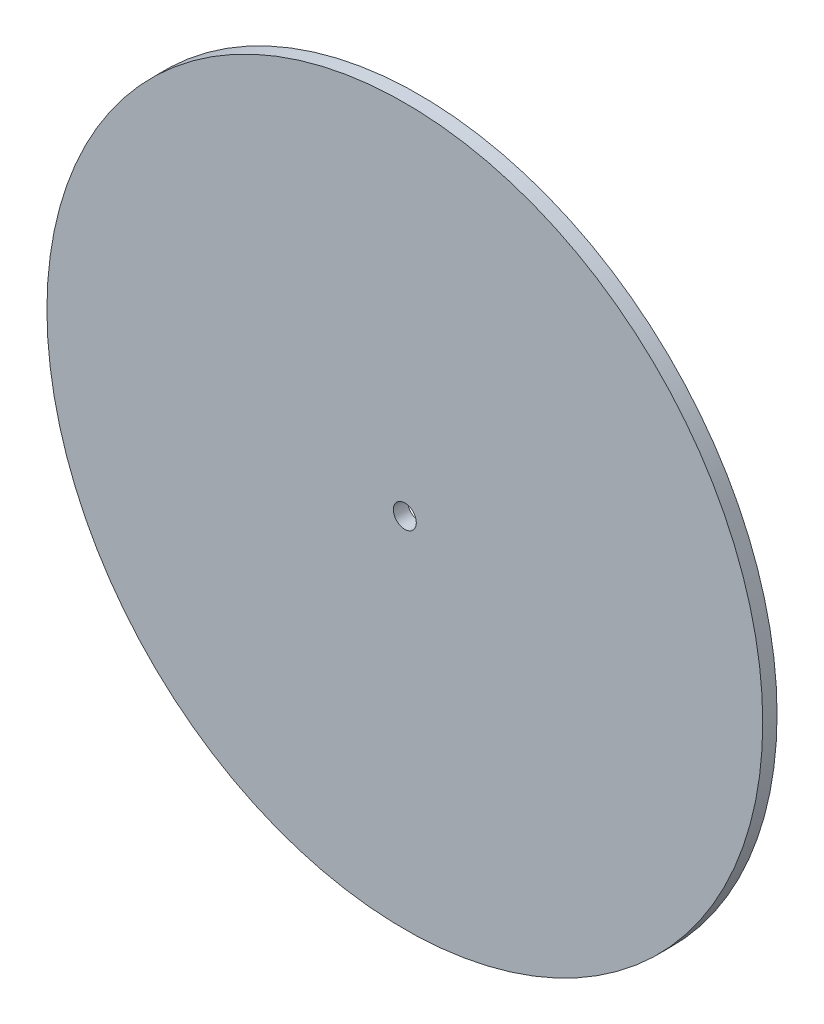
from build123d import *

# Parameters (mm, degrees)
SKETCH1_R           = 62.5
SKETCH1_R_2         = 2
BOSS_EXTRUDE1_DEPTH = 2.5


with BuildPart() as part:
    # Sketch1 → Boss-Extrude1 (new body)
    with BuildSketch(Plane.XY):
        Circle(SKETCH1_R)
        Circle(SKETCH1_R_2, mode=Mode.SUBTRACT)
    extrude(amount=BOSS_EXTRUDE1_DEPTH)


solid = part.part
